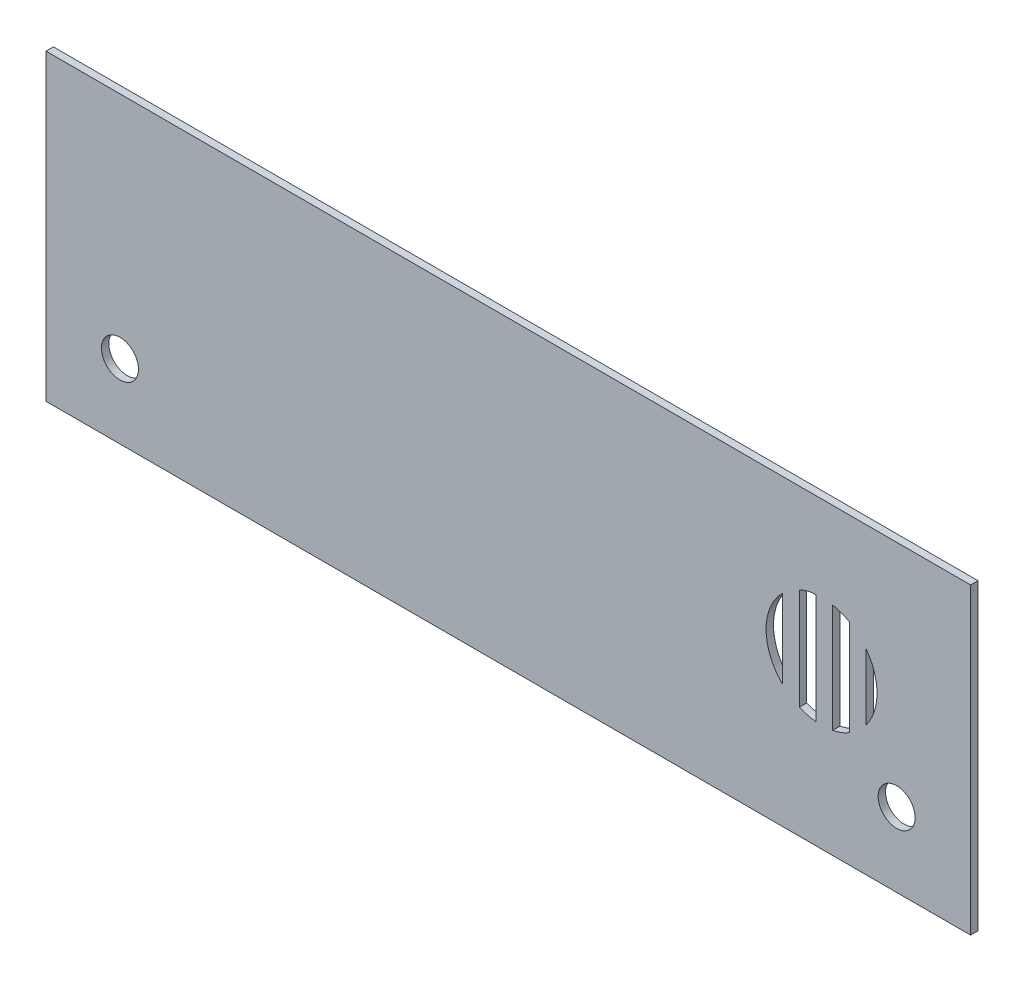
from build123d import *

# Parameters (mm, degrees)
SKETCH1_W           = 250
SKETCH1_H           = 82
BOSS_EXTRUDE1_DEPTH = 2
CUT_EXTRUDE1_DEPTH  = 3
SKETCH3_R           = 5
CUT_EXTRUDE2_DEPTH  = 3


with BuildPart() as part:
    # Sketch1 → Boss-Extrude1 (new body)
    with BuildSketch(Plane.XY):
        Rectangle(SKETCH1_W, SKETCH1_H)
    extrude(amount=BOSS_EXTRUDE1_DEPTH)

    # Sketch2 → Cut-Extrude1 (cut)
    with BuildSketch(Plane.XY.offset(2)):
        with BuildLine():
            ThreePointArc((74.195797737, 13.695923098), (70.866481051, 8.793255475), (69.695797737, 2.983780456))
            ThreePointArc((69.695797737, 2.983780456), (70.866481051, -2.825694564), (74.195797737, -7.728362187))
            Line((74.195797737, -7.728362187), (74.195797737, 13.695923098))
        make_face()
        with BuildLine():
            Line((83.195797737, 17.773650373), (82.193848931, 17.773650373))
            ThreePointArc((82.193848931, 17.773650373), (80.413006732, 17.359374398), (78.695797737, 16.73150754))
            Line((78.695797737, 16.73150754), (78.695797737, -10.763946629))
            ThreePointArc((78.695797737, -10.763946629), (80.899894424, -11.527977468), (83.195797737, -11.941031101))
            Line((83.195797737, -11.941031101), (83.195797737, 17.773650373))
        make_face()
        with BuildLine():
            ThreePointArc((92.195797737, 15.974161512), (90.014687146, 17.009093837), (87.695797737, 17.680718912))
            Line((87.695797737, 17.680718912), (87.695797737, -11.713158001))
            ThreePointArc((87.695797737, -11.713158001), (90.014687146, -11.041532926), (92.195797737, -10.006600601))
            Line((92.195797737, -10.006600601), (92.195797737, 15.974161512))
        make_face()
        with BuildLine():
            ThreePointArc((99.695797737, 2.983780456), (98.926047208, 7.727196946), (96.695797737, 11.983780456))
            Line((96.695797737, 11.983780456), (96.695797737, -6.016219544))
            ThreePointArc((96.695797737, -6.016219544), (98.926047208, -1.759636035), (99.695797737, 2.983780456))
        make_face()
    extrude(amount=-CUT_EXTRUDE1_DEPTH, mode=Mode.SUBTRACT)

    # Sketch3 → Cut-Extrude2 (cut)
    with BuildSketch(Plane.XY.offset(2)):
        with Locations((-105, -21)):
            Circle(SKETCH3_R)
        with Locations((105, -21)):
            Circle(SKETCH3_R)
    extrude(amount=-CUT_EXTRUDE2_DEPTH, mode=Mode.SUBTRACT)


solid = part.part
